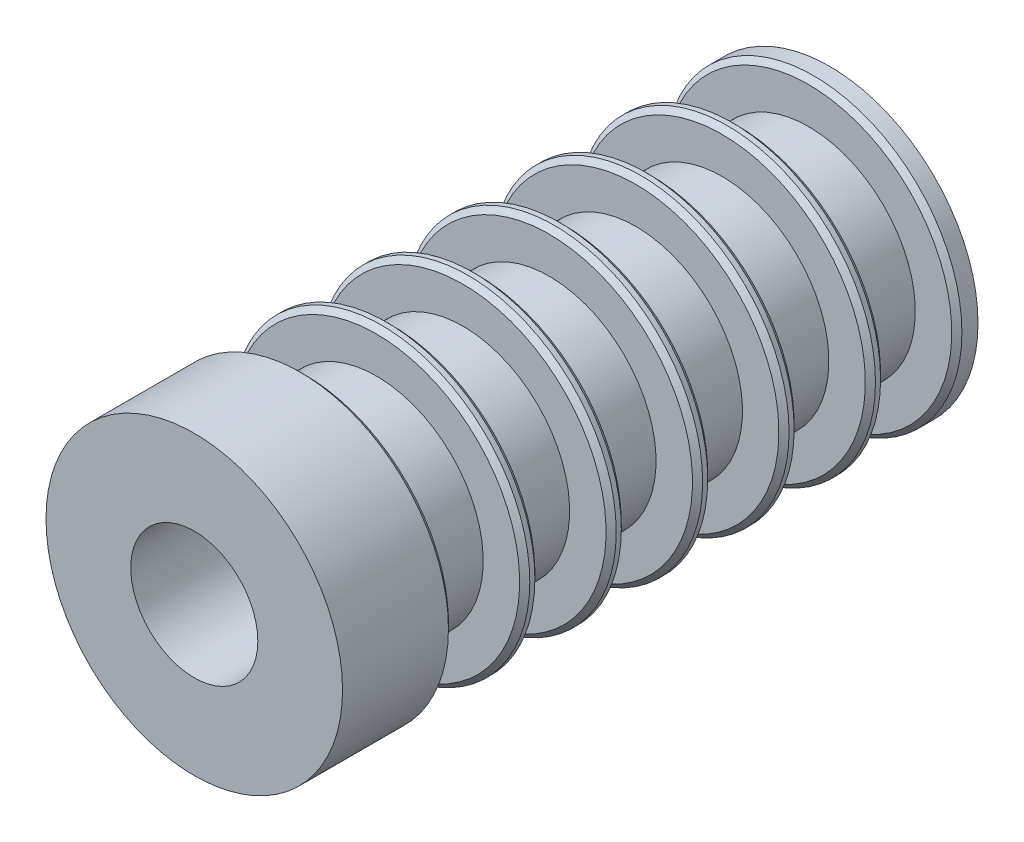
from build123d import *

# Parameters (mm, degrees)
SKETCH1_R                  = 11.1125
SKETCH1_R_2                = 3.2004
EXTRUDE1_DEPTH             = 25.4
SKETCH5_R                  = 11.1125
SKETCH5_R_2                = 3.2004
CUT_EXTRUDE1_DEPTH         = 3.175
SKETCH6_R                  = 4.7625
CUT_EXTRUDE2_DEPTH         = 48.625
CUT_EXTRUDE3_START         = -1.5875
SKETCH7_R                  = 11.1125
SKETCH7_R_2                = 8.001
CUT_EXTRUDE3_DEPTH         = 5.334
CHAMFER2_SIZE              = 0.381
LPATTERN1_COUNT            = 6
LPATTERN1_PITCH            = 6.477
CHAMFER2_OF_LPATTERN1_SIZE = 0.381


with BuildPart() as part:
    # Sketch1 → Extrude1 (new body, symmetric)
    with BuildSketch(Plane.XY):
        Circle(SKETCH1_R)
        Circle(SKETCH1_R_2, mode=Mode.SUBTRACT)
    extrude(amount=EXTRUDE1_DEPTH, both=True)

    # Sketch5 → Cut-Extrude1 (cut)
    with BuildSketch(Plane.XY.offset(25.4)):
        Circle(SKETCH5_R)
        Circle(SKETCH5_R_2, mode=Mode.SUBTRACT)
    extrude(amount=-CUT_EXTRUDE1_DEPTH, mode=Mode.SUBTRACT)

    # Sketch6 → Cut-Extrude2 (cut, through all)
    with BuildSketch(Plane.XY.offset(22.225)):
        Circle(SKETCH6_R)
    extrude(amount=-CUT_EXTRUDE2_DEPTH, mode=Mode.SUBTRACT)

    # Sketch7 → Cut-Extrude3 (cut)
    with BuildSketch(Plane(origin=(0, 0, -25.4), x_dir=(-1, 0, 0), z_dir=(0, 0, -1)).offset(CUT_EXTRUDE3_START)):
        Circle(SKETCH7_R)
        Circle(SKETCH7_R_2, mode=Mode.SUBTRACT)
    cut_extrude3 = extrude(amount=-CUT_EXTRUDE3_DEPTH, mode=Mode.SUBTRACT)

    # Chamfer2
    chamfer2_edges = [part.edges().sort_by_distance(p)[0] for p in [
        (-11.1125, 0, -18.4785),
        (-11.1125, 0, -23.8125),
    ]]
    chamfer(chamfer2_edges, length=CHAMFER2_SIZE)

    # LPattern1: Cut-Extrude3 ×6
    with Locations(*[(0, 0, i * LPATTERN1_PITCH) for i in range(1, LPATTERN1_COUNT)]):
        add(cut_extrude3, mode=Mode.SUBTRACT)

    # Chamfer2 of LPattern1
    chamfer2_of_lpattern1_edges = [part.edges().sort_by_distance(p)[0] for p in [
        (-11.1125, 0, -12.0015),
        (-11.1125, 0, -17.3355),
        (-11.1125, 0, -5.5245),
        (-11.1125, 0, -10.8585),
        (-11.1125, 0, 0.9525),
        (-11.1125, 0, -4.3815),
        (-11.1125, 0, 7.4295),
        (-11.1125, 0, 2.0955),
        (-11.1125, 0, 13.9065),
        (-11.1125, 0, 8.5725),
    ]]
    chamfer(chamfer2_of_lpattern1_edges, length=CHAMFER2_OF_LPATTERN1_SIZE)


solid = part.part
